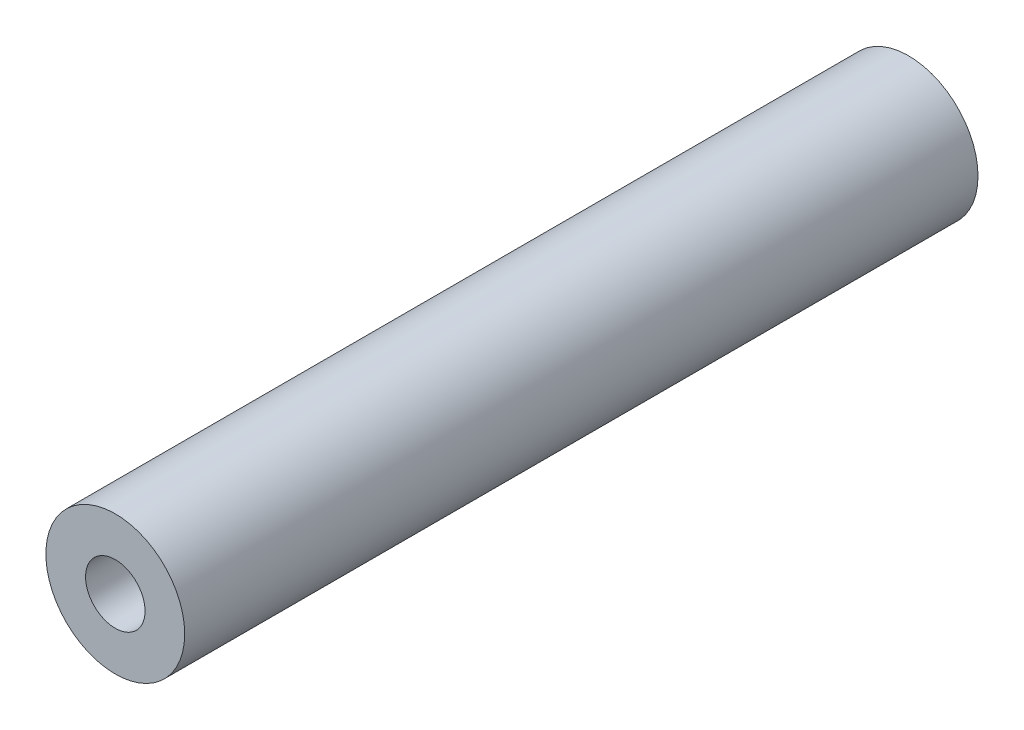
from build123d import *

# Parameters (mm, degrees)
CROQUIS1_R              = 3.5
SALIENTE_EXTRUIR1_DEPTH = 40
CROQUIS2_R              = 1.5
CORTAR_EXTRUIR1_DEPTH   = 15
CROQUIS3_R              = 2
CORTAR_EXTRUIR2_DEPTH   = 15
CROQUIS4_R              = 1.4
CORTAR_EXTRUIR3_DEPTH   = 4.5


with BuildPart() as part:
    # Croquis1 → Saliente-Extruir1 (new body)
    with BuildSketch(Plane.XY):
        Circle(CROQUIS1_R)
    extrude(amount=SALIENTE_EXTRUIR1_DEPTH)

    # Croquis2 → Cortar-Extruir1 (cut)
    with BuildSketch(Plane.XY.offset(40)):
        Circle(CROQUIS2_R)
    extrude(amount=-CORTAR_EXTRUIR1_DEPTH, mode=Mode.SUBTRACT)

    # Croquis3 → Cortar-Extruir2 (cut)
    with BuildSketch(Plane(origin=(0, 0, 0), x_dir=(-1, 0, 0), z_dir=(0, 0, -1))):
        Circle(CROQUIS3_R)
    extrude(amount=-CORTAR_EXTRUIR2_DEPTH, mode=Mode.SUBTRACT)

    # Croquis4 → Cortar-Extruir3 (cut, through all)
    with BuildSketch(Plane(origin=(0, 0, 0), x_dir=(1, 0, 0), z_dir=(0, 1, 0))):
        with Locations((0, -4)):
            Circle(CROQUIS4_R)
        with Locations((0, -36)):
            Circle(CROQUIS4_R)
    extrude(amount=-CORTAR_EXTRUIR3_DEPTH, mode=Mode.SUBTRACT)


solid = part.part
